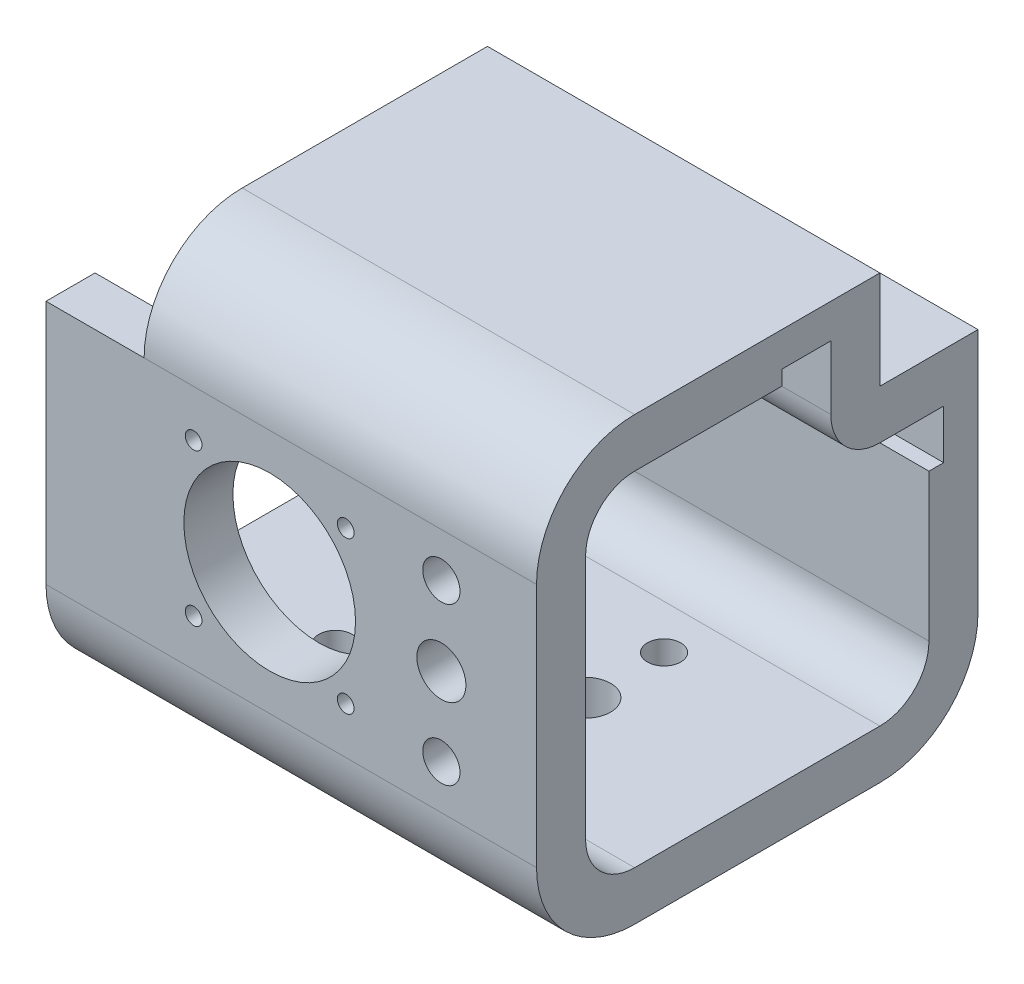
from build123d import *

# Parameters (mm, degrees)
BOSS_EXTRUDE1_DEPTH      = 54.4
BOSS_EXTRUDE1_DEPTH_BACK = 45.6
CUT_EXTRUDE1_REACH       = 92
SKETCH3_R                = 3.8
SKETCH3_R_2              = 5
SKETCH3_R_3              = 17.5
SKETCH3_R_4              = 1.7
CUT_EXTRUDE2_REACH       = 92
SKETCH4_R                = 5.1
SKETCH4_R_2              = 5.099999999
SKETCH4_R_3              = 3.4
SKETCH6_W                = 20
SKETCH6_H                = 20
CUT_EXTRUDE4_DEPTH       = 91
SKETCH7_W                = 20
SKETCH7_H                = 20
CUT_EXTRUDE5_DEPTH       = 91
SKETCH5_W                = 3
SKETCH5_H                = 20
SKETCH5_W_2              = 20
SKETCH5_H_2              = 3
CUT_EXTRUDE3_DEPTH       = 101
BOSS_EXTRUDE2_DEPTH      = 80


with BuildPart() as part:
    # Sketch2 → Boss-Extrude1 (new body, two sides)
    with BuildSketch(Plane(origin=(0, 0, 0), x_dir=(0, 0, -1), z_dir=(1, 0, 0))) as boss_extrude1_sk:
        with BuildLine():
            Line((-30.8, -44.997596663), (19.2, -44.997596663))
            ThreePointArc((19.2, -44.997596663), (33.342135624, -39.139732287), (39.2, -24.997596663))
            Line((39.2, -24.997596663), (39.2, 25.002403337))
            ThreePointArc((39.2, 25.002403337), (33.342135624, 39.144538961), (19.2, 45.002403337))
            Line((19.2, 45.002403337), (-30.8, 45.002403337))
            ThreePointArc((-30.8, 45.002403337), (-44.942135624, 39.144538961), (-50.8, 25.002403337))
            Line((-50.8, 25.002403337), (-50.8, -24.997596663))
            ThreePointArc((-50.8, -24.997596663), (-44.942135624, -39.139732287), (-30.8, -44.997596663))
        make_face()
        with BuildLine():
            Line((-30.8, 35.002403337), (19.2, 35.002403337))
            ThreePointArc((19.2, 35.002403337), (26.271067812, 32.073471149), (29.2, 25.002403337))
            Line((29.2, 25.002403337), (29.2, -24.997596663))
            ThreePointArc((29.2, -24.997596663), (26.271067812, -32.068664475), (19.2, -34.997596663))
            Line((19.2, -34.997596663), (-30.8, -34.997596663))
            ThreePointArc((-30.8, -34.997596663), (-37.871067812, -32.068664475), (-40.8, -24.997596663))
            Line((-40.8, -24.997596663), (-40.8, 25.002403337))
            ThreePointArc((-40.8, 25.002403337), (-37.871067812, 32.073471149), (-30.8, 35.002403337))
        make_face(mode=Mode.SUBTRACT)
    extrude(amount=BOSS_EXTRUDE1_DEPTH)
    extrude(boss_extrude1_sk.sketch, amount=-BOSS_EXTRUDE1_DEPTH_BACK)

    # Sketch3 → Cut-Extrude1 (cut, up to next)
    with BuildSketch(Plane.XY.offset(50.8), mode=Mode.PRIVATE) as cut_extrude1_sk1:
        with Locations((35, -16)):
            Circle(SKETCH3_R)
    cut_extrude1_tool1 = extrude(cut_extrude1_sk1.sketch, amount=-CUT_EXTRUDE1_REACH, mode=Mode.PRIVATE) & part.part
    add(cut_extrude1_tool1.solids().sort_by_distance((35, -16, 50.8))[0], mode=Mode.SUBTRACT)
    # Sketch3 → Cut-Extrude1 (cut, up to next)
    with BuildSketch(Plane.XY.offset(50.8), mode=Mode.PRIVATE) as cut_extrude1_sk2:
        with Locations((35, 0)):
            Circle(SKETCH3_R_2)
    cut_extrude1_tool2 = extrude(cut_extrude1_sk2.sketch, amount=-CUT_EXTRUDE1_REACH, mode=Mode.PRIVATE) & part.part
    add(cut_extrude1_tool2.solids().sort_by_distance((35, 0, 50.8))[0], mode=Mode.SUBTRACT)
    # Sketch3 → Cut-Extrude1 (cut, up to next)
    with BuildSketch(Plane.XY.offset(50.8), mode=Mode.PRIVATE) as cut_extrude1_sk3:
        with Locations((35, 16)):
            Circle(SKETCH3_R)
    cut_extrude1_tool3 = extrude(cut_extrude1_sk3.sketch, amount=-CUT_EXTRUDE1_REACH, mode=Mode.PRIVATE) & part.part
    add(cut_extrude1_tool3.solids().sort_by_distance((35, 16, 50.8))[0], mode=Mode.SUBTRACT)
    # Sketch3 → Cut-Extrude1 (cut, up to next)
    with BuildSketch(Plane.XY.offset(50.8), mode=Mode.PRIVATE) as cut_extrude1_sk4:
        Circle(SKETCH3_R_3)
    cut_extrude1_tool4 = extrude(cut_extrude1_sk4.sketch, amount=-CUT_EXTRUDE1_REACH, mode=Mode.PRIVATE) & part.part
    add(cut_extrude1_tool4.solids().sort_by_distance((0, 0, 50.8))[0], mode=Mode.SUBTRACT)
    # Sketch3 → Cut-Extrude1 (cut, up to next)
    with BuildSketch(Plane.XY.offset(50.8), mode=Mode.PRIVATE) as cut_extrude1_sk5:
        with Locations((15.5, 15.5)):
            Circle(SKETCH3_R_4)
    cut_extrude1_tool5 = extrude(cut_extrude1_sk5.sketch, amount=-CUT_EXTRUDE1_REACH, mode=Mode.PRIVATE) & part.part
    add(cut_extrude1_tool5.solids().sort_by_distance((15.5, 15.5, 50.8))[0], mode=Mode.SUBTRACT)
    # Sketch3 → Cut-Extrude1 (cut, up to next)
    with BuildSketch(Plane.XY.offset(50.8), mode=Mode.PRIVATE) as cut_extrude1_sk6:
        with Locations((15.5, -15.5)):
            Circle(SKETCH3_R_4)
    cut_extrude1_tool6 = extrude(cut_extrude1_sk6.sketch, amount=-CUT_EXTRUDE1_REACH, mode=Mode.PRIVATE) & part.part
    add(cut_extrude1_tool6.solids().sort_by_distance((15.5, -15.5, 50.8))[0], mode=Mode.SUBTRACT)
    # Sketch3 → Cut-Extrude1 (cut, up to next)
    with BuildSketch(Plane.XY.offset(50.8), mode=Mode.PRIVATE) as cut_extrude1_sk7:
        with Locations((-15.5, 15.5)):
            Circle(SKETCH3_R_4)
    cut_extrude1_tool7 = extrude(cut_extrude1_sk7.sketch, amount=-CUT_EXTRUDE1_REACH, mode=Mode.PRIVATE) & part.part
    add(cut_extrude1_tool7.solids().sort_by_distance((-15.5, 15.5, 50.8))[0], mode=Mode.SUBTRACT)
    # Sketch3 → Cut-Extrude1 (cut, up to next)
    with BuildSketch(Plane.XY.offset(50.8), mode=Mode.PRIVATE) as cut_extrude1_sk8:
        with Locations((-15.5, -15.5)):
            Circle(SKETCH3_R_4)
    cut_extrude1_tool8 = extrude(cut_extrude1_sk8.sketch, amount=-CUT_EXTRUDE1_REACH, mode=Mode.PRIVATE) & part.part
    add(cut_extrude1_tool8.solids().sort_by_distance((-15.5, -15.5, 50.8))[0], mode=Mode.SUBTRACT)

    # Sketch4 → Cut-Extrude2 (cut, up to next)
    with BuildSketch(Plane.XZ.offset(44.997596663), mode=Mode.PRIVATE) as cut_extrude2_sk1:
        with Locations((-15.6, 5.8)):
            Circle(SKETCH4_R)
    cut_extrude2_tool1 = extrude(cut_extrude2_sk1.sketch, amount=-CUT_EXTRUDE2_REACH, mode=Mode.PRIVATE) & part.part
    add(cut_extrude2_tool1.solids().sort_by_distance((-15.6, -44.997597, 5.8))[0], mode=Mode.SUBTRACT)
    # Sketch4 → Cut-Extrude2 (cut, up to next)
    with BuildSketch(Plane.XZ.offset(44.997596663), mode=Mode.PRIVATE) as cut_extrude2_sk2:
        with Locations((19.4, 5.8)):
            Circle(SKETCH4_R_2)
    cut_extrude2_tool2 = extrude(cut_extrude2_sk2.sketch, amount=-CUT_EXTRUDE2_REACH, mode=Mode.PRIVATE) & part.part
    add(cut_extrude2_tool2.solids().sort_by_distance((19.4, -44.997597, 5.8))[0], mode=Mode.SUBTRACT)
    # Sketch4 → Cut-Extrude2 (cut, up to next)
    with BuildSketch(Plane.XZ.offset(44.997596663), mode=Mode.PRIVATE) as cut_extrude2_sk3:
        with Locations((-15.6, 21.8)):
            Circle(SKETCH4_R_3)
    cut_extrude2_tool3 = extrude(cut_extrude2_sk3.sketch, amount=-CUT_EXTRUDE2_REACH, mode=Mode.PRIVATE) & part.part
    add(cut_extrude2_tool3.solids().sort_by_distance((-15.6, -44.997597, 21.8))[0], mode=Mode.SUBTRACT)
    # Sketch4 → Cut-Extrude2 (cut, up to next)
    with BuildSketch(Plane.XZ.offset(44.997596663), mode=Mode.PRIVATE) as cut_extrude2_sk4:
        with Locations((-15.6, -10.2)):
            Circle(SKETCH4_R_3)
    cut_extrude2_tool4 = extrude(cut_extrude2_sk4.sketch, amount=-CUT_EXTRUDE2_REACH, mode=Mode.PRIVATE) & part.part
    add(cut_extrude2_tool4.solids().sort_by_distance((-15.6, -44.997597, -10.2))[0], mode=Mode.SUBTRACT)
    # Sketch4 → Cut-Extrude2 (cut, up to next)
    with BuildSketch(Plane.XZ.offset(44.997596663), mode=Mode.PRIVATE) as cut_extrude2_sk5:
        with Locations((19.4, 21.8)):
            Circle(SKETCH4_R_3)
    cut_extrude2_tool5 = extrude(cut_extrude2_sk5.sketch, amount=-CUT_EXTRUDE2_REACH, mode=Mode.PRIVATE) & part.part
    add(cut_extrude2_tool5.solids().sort_by_distance((19.4, -44.997597, 21.8))[0], mode=Mode.SUBTRACT)
    # Sketch4 → Cut-Extrude2 (cut, up to next)
    with BuildSketch(Plane.XZ.offset(44.997596663), mode=Mode.PRIVATE) as cut_extrude2_sk6:
        with Locations((19.4, -10.2)):
            Circle(SKETCH4_R_3)
    cut_extrude2_tool6 = extrude(cut_extrude2_sk6.sketch, amount=-CUT_EXTRUDE2_REACH, mode=Mode.PRIVATE) & part.part
    add(cut_extrude2_tool6.solids().sort_by_distance((19.4, -44.997597, -10.2))[0], mode=Mode.SUBTRACT)

    # Sketch6 → Cut-Extrude4 (cut, through all)
    with BuildSketch(Plane(origin=(0, 0, -39.2), x_dir=(-1, 0, 0), z_dir=(0, 0, -1))):
        with Locations((35.6, 35.002403337)):
            Rectangle(SKETCH6_W, SKETCH6_H)
    extrude(amount=-CUT_EXTRUDE4_DEPTH, mode=Mode.SUBTRACT)

    # Sketch7 → Cut-Extrude5 (cut, through all)
    with BuildSketch(Plane.XZ.offset(44.997596663)):
        with Locations((-35.6, -29.2)):
            Rectangle(SKETCH7_W, SKETCH7_H)
    extrude(amount=-CUT_EXTRUDE5_DEPTH, mode=Mode.SUBTRACT)

    # Sketch5 → Cut-Extrude3 (cut, through all)
    with BuildSketch(Plane.ZY.offset(45.6)):
        Polygon((-29.2, 25.002403337), (-19.2, 25.002403337), (-19.2, 35.002403337), (-19.2, 38.002403337), (-19.2, 45.002403337), (-39.2, 45.002403337), (-39.2, 25.002403337), (-32.2, 25.002403337), align=None)
        with Locations((-30.7, 15.002403337)):
            Rectangle(SKETCH5_W, SKETCH5_H)
        with Locations((-9.2, 36.502403337)):
            Rectangle(SKETCH5_W_2, SKETCH5_H_2)
    extrude(amount=-CUT_EXTRUDE3_DEPTH, mode=Mode.SUBTRACT)

    # Sketch8 → Boss-Extrude2 (add)
    with BuildSketch(Plane.ZY.offset(25.6)):
        with BuildLine():
            Line((-19.2, 38.002403337), (-19.2, 25.002403337))
            Line((-19.2, 25.002403337), (-32.2, 25.002403337))
            Line((-32.2, 25.002403337), (-32.2, 15.002403337))
            Line((-32.2, 15.002403337), (-19.2, 15.002403337))
            ThreePointArc((-19.2, 15.002403337), (-12.128932188, 17.931335525), (-9.2, 25.002403337))
            Line((-9.2, 25.002403337), (-9.2, 38.002403337))
            Line((-9.2, 38.002403337), (-19.2, 38.002403337))
        make_face()
    extrude(amount=-BOSS_EXTRUDE2_DEPTH)


solid = part.part
